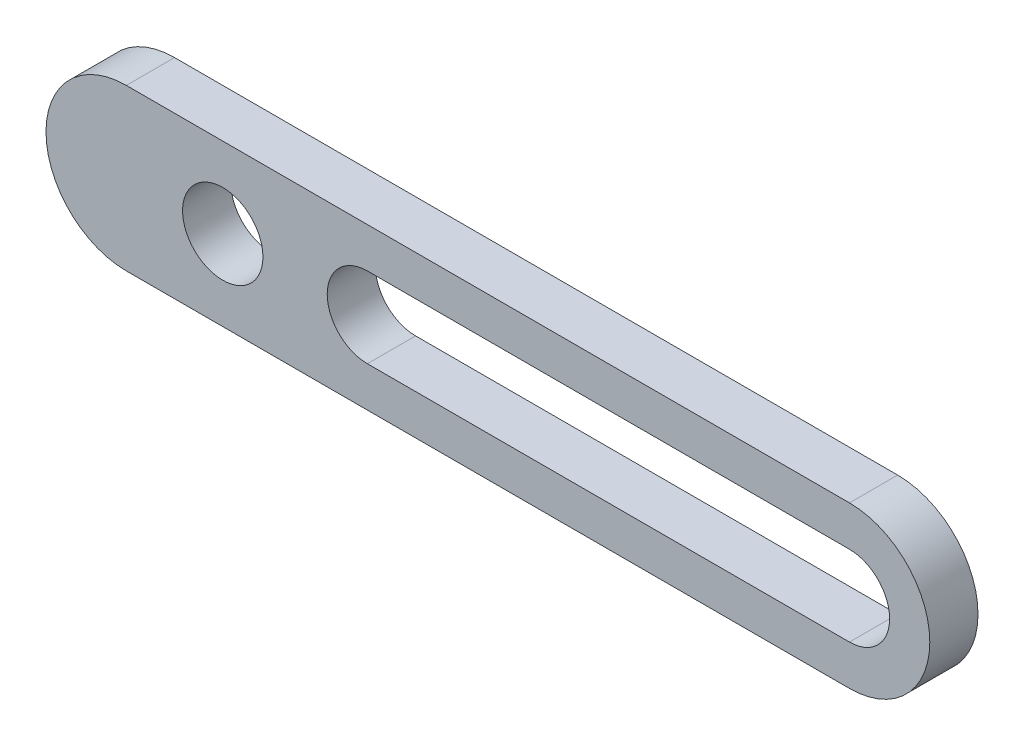
from build123d import *

# Parameters (mm, degrees)
SKETCH2_R           = 2.5
BOSS_EXTRUDE1_DEPTH = 3


with BuildPart() as part:
    # Sketch2 → Boss-Extrude1 (new body)
    with BuildSketch(Plane.XY):
        with BuildLine():
            Line((2.152494721, 5.855657737), (47.152494721, 5.855657737))
            ThreePointArc((47.152494721, 5.855657737), (52.152494721, 0.855657737), (47.152494721, -4.144342263))
            Line((47.152494721, -4.144342263), (2.152494721, -4.144342263))
            ThreePointArc((2.152494721, -4.144342263), (-2.847505279, 0.855657737), (2.152494721, 5.855657737))
        make_face()
        with Locations((8.152494721, 0.855657737)):
            Circle(SKETCH2_R, mode=Mode.SUBTRACT)
        with BuildLine():
            Line((17.152494721, 3.355657737), (47.152494721, 3.355657737))
            ThreePointArc((47.152494721, 3.355657737), (49.652494721, 0.855657737), (47.152494721, -1.644342263))
            Line((47.152494721, -1.644342263), (17.152494721, -1.644342263))
            ThreePointArc((17.152494721, -1.644342263), (14.652494721, 0.855657737), (17.152494721, 3.355657737))
        make_face(mode=Mode.SUBTRACT)
    extrude(amount=BOSS_EXTRUDE1_DEPTH)


solid = part.part
